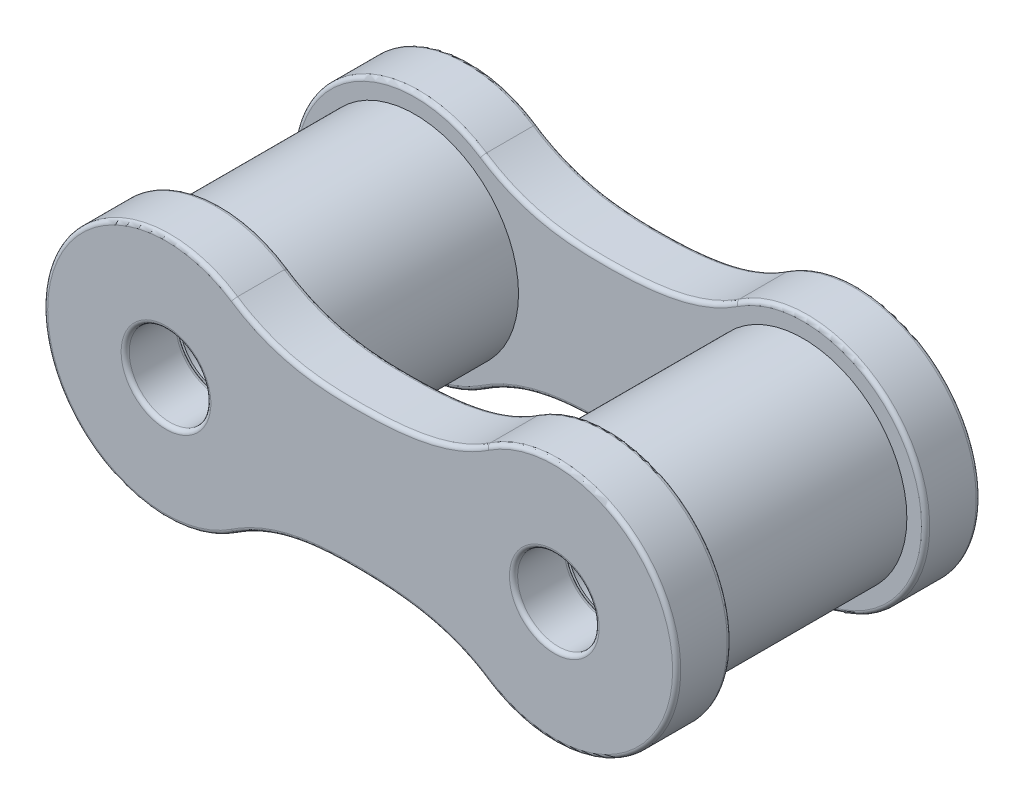
from build123d import *

# Parameters (mm, degrees)
SKETCH2_R           = 1
BOSS_EXTRUDE1_DEPTH = 1.3425
FILLET1_R           = 0.1
SKETCH3_R           = 2.54
SKETCH3_R_2         = 1
BOSS_EXTRUDE2_DEPTH = 4.76


with BuildPart() as part:
    # Sketch2 → Boss-Extrude1 (new body)
    with BuildSketch(Plane.XY):
        with BuildLine():
            ThreePointArc((-3.101687605, 2.5), (-7.76, 0), (-3.101687605, -2.5))
            add(Edge.make_bspline(
                [(-3.101687605, -2.5), (-2.103560278, -1.837917233), (-0.030939489, -1.641559832), (2.165439256, -1.878963103), (3.101687605, -2.5)],
                knots=[0, 0, 0, 0, 0.5, 1, 1, 1, 1], degree=3))
            ThreePointArc((3.101687605, -2.5), (7.76, 0), (3.101687605, 2.5))
            add(Edge.make_bspline(
                [(-3.101687605, 2.5), (-2.103560278, 1.837917233), (-0.030939489, 1.641559832), (2.165439256, 1.878963103), (3.101687605, 2.5)],
                knots=[0, 0, 0, 0, 0.5, 1, 1, 1, 1], degree=3))
        make_face()
        with Locations((-4.76, 0)):
            Circle(SKETCH2_R, mode=Mode.SUBTRACT)
        with Locations((4.76, 0)):
            Circle(SKETCH2_R, mode=Mode.SUBTRACT)
    extrude(amount=BOSS_EXTRUDE1_DEPTH)

    # Fillet1
    fillet1_edges = [part.edges().sort_by_distance(p)[0] for p in [
        (-0.002993558, -1.749971501, 1.3425),
        (-5.76, 0, 0),
        (-5.76, 0, 1.3425),
        (7.76, 0, 1.3425),
        (3.76, 0, 0),
        (3.76, 0, 1.3425),
        (-0.002993558, 1.749971501, 1.3425),
        (7.76, 0, 0),
        (-0.002993558, -1.749971501, 0),
        (-7.76, 0, 0),
        (-0.002993558, 1.749971501, 0),
        (-7.76, 0, 1.3425),
    ]]
    fillet(fillet1_edges, radius=FILLET1_R)

    # Sketch3 → Boss-Extrude2 (add)
    with BuildSketch(Plane.XY.offset(1.3425)):
        with Locations((-4.76, 0)):
            Circle(SKETCH3_R)
        with Locations((-4.76, 0)):
            Circle(SKETCH3_R_2, mode=Mode.SUBTRACT)
        with Locations((4.76, 0)):
            Circle(SKETCH3_R)
        with Locations((4.76, 0)):
            Circle(SKETCH3_R_2, mode=Mode.SUBTRACT)
    extrude(amount=BOSS_EXTRUDE2_DEPTH)

    # Mirror1: part across plane


with BuildPart() as part_1:
    add(part.part)
    add(part.part.mirror(Plane.XY.offset(3.7225)))


solid = part_1.part
